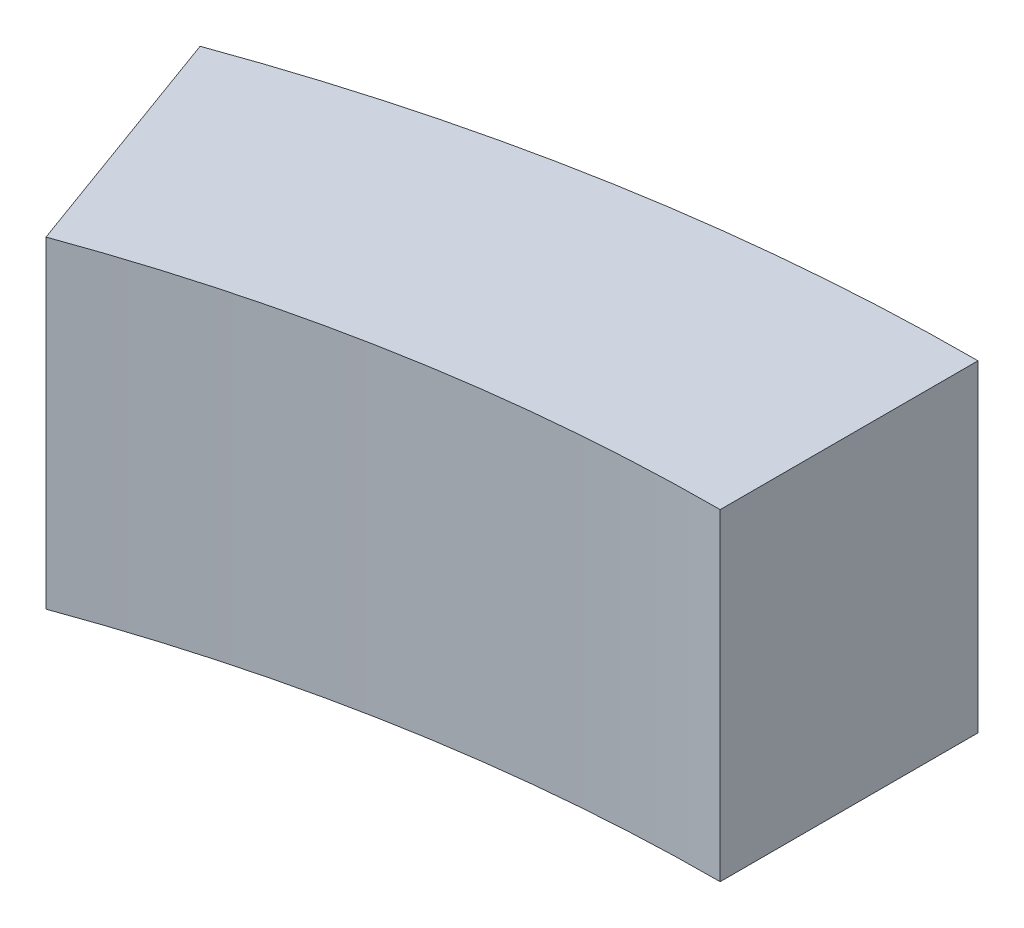
from build123d import *

# Parameters (mm, degrees)
AUFSATZ_LINEAR_AUSTRAGEN1_DEPTH = 10


with BuildPart() as part:
    # Skizze1 → Aufsatz-Linear austragen1 (new body)
    with BuildSketch(Plane(origin=(0, 0, 0), x_dir=(1, 0, 0), z_dir=(0, 1, 0))):
        with BuildLine():
            Line((-20.5212086, 56.381557247), (-17.785047453, 48.864016281))
            ThreePointArc((-17.785047453, 48.864016281), (-9.029705239, 51.210003157), (0, 52))
            Line((0, 52), (0, 60))
            ThreePointArc((0, 60), (-10.41889066, 59.088465181), (-20.5212086, 56.381557247))
        make_face()
    extrude(amount=AUFSATZ_LINEAR_AUSTRAGEN1_DEPTH)


solid = part.part
